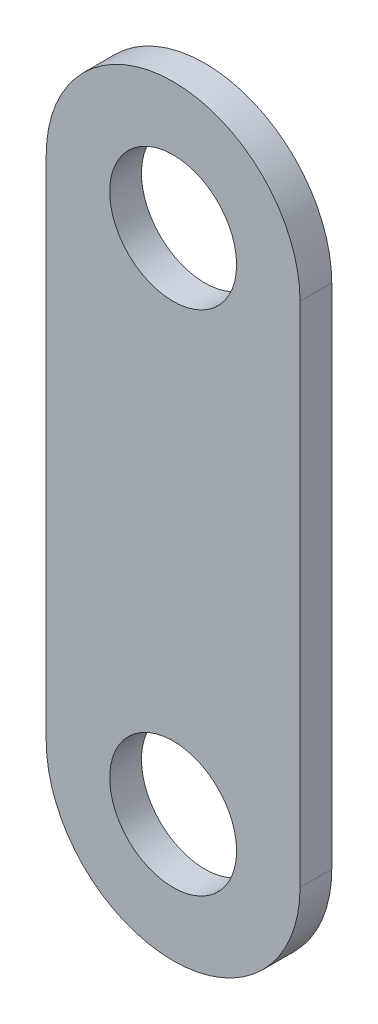
from build123d import *

# Parameters (mm, degrees)
SKETCH1_R           = 12.7
SKETCH1_R_2         = 6.35
BOSS_EXTRUDE1_DEPTH = 3.175


with BuildPart() as part:
    # Sketch1 → Boss-Extrude1 (new body)
    with BuildSketch(Plane.XY):
        with Locations((-17.213222871, 25.742348898)):
            Circle(SKETCH1_R)
        with Locations((-17.213222871, 25.742348898)):
            Circle(SKETCH1_R_2, mode=Mode.SUBTRACT)
        with BuildLine():
            Line((-29.913222871, 25.742348898), (-29.913222871, -25.057651102))
            ThreePointArc((-29.913222871, -25.057651102), (-17.213222871, -12.357651102), (-4.513222871, -25.057651102))
            Line((-4.513222871, -25.057651102), (-4.513222871, 25.742348898))
            ThreePointArc((-4.513222871, 25.742348898), (-17.213222871, 13.042348898), (-29.913222871, 25.742348898))
        make_face()
        with Locations((-17.213222871, -25.057651102)):
            Circle(SKETCH1_R)
        with Locations((-17.213222871, -25.057651102)):
            Circle(SKETCH1_R_2, mode=Mode.SUBTRACT)
    extrude(amount=BOSS_EXTRUDE1_DEPTH)


solid = part.part
